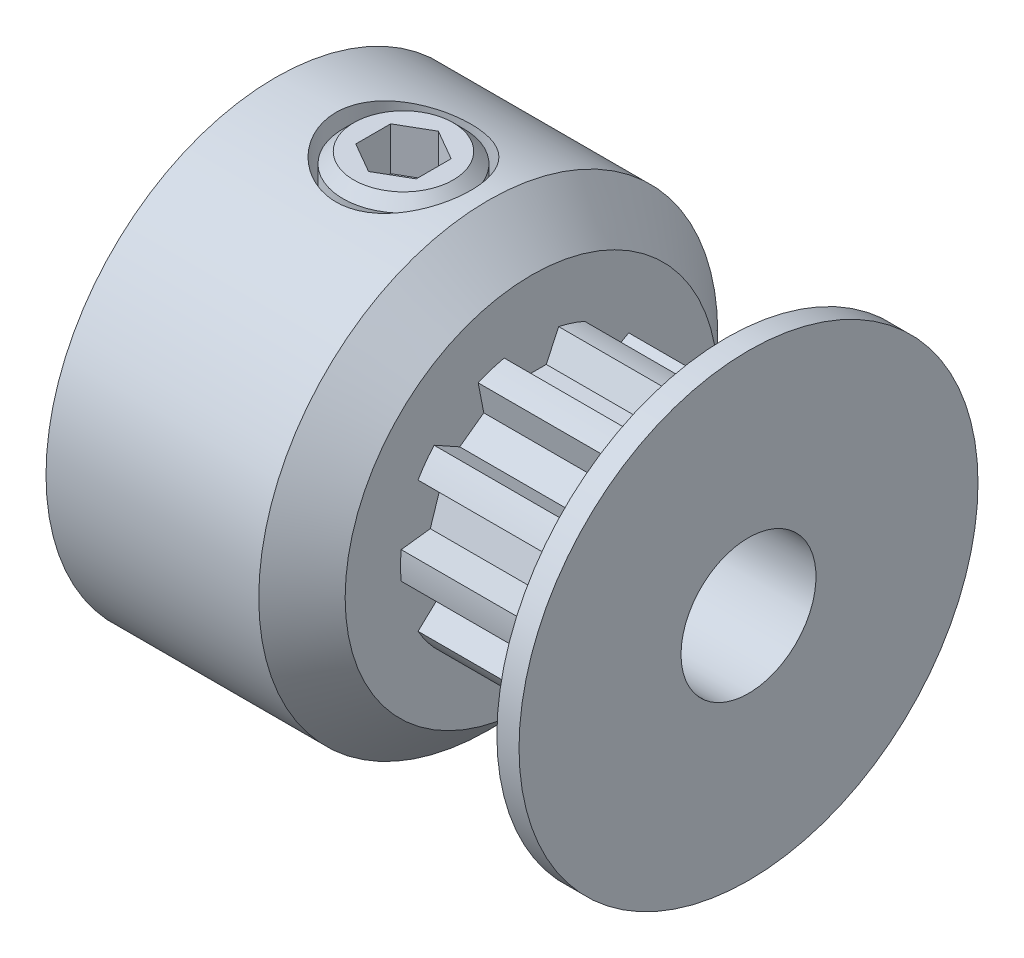
from build123d import *

# Parameters (mm, degrees)
SKETCH4_R          = 3.2385
SKETCH4_R_2        = 3.07975
CUT_EXTRUDE2_DEPTH = 4.064
CUT_EXTRUDE1_DEPTH = 4.064
CIRPATTERN1_COUNT  = 10
SKETCH6_R          = 1.5875
CUT_EXTRUDE3_DEPTH = 6.3975
CUT_EXTRUDE4_DEPTH = 1.016


with BuildPart() as part:
    # Sketch1 → Revolve1 (revolve)
    with BuildSketch(Plane.XY):
        with BuildLine():
            Line((-5.5626, 1.5875), (5.5626, 1.5875))
            Line((5.5626, 1.5875), (5.5626, 5.3975))
            Line((5.5626, 5.3975), (5.0419, 5.3975))
            ThreePointArc((5.0419, 5.3975), (4.654699632, 4.645356921), (4.5212, 3.81))
            Line((4.5212, 3.81), (4.5212, 3.2385))
            Line((4.5212, 3.2385), (0.4572, 3.2385))
            Line((0.4572, 3.2385), (0.4572, 4.3815))
            Line((0.4572, 4.3815), (-0.5588, 5.3975))
            Line((-0.5588, 5.3975), (-5.5626, 5.3975))
            Line((-5.5626, 5.3975), (-5.5626, 1.5875))
        make_face()
    revolve(axis=Axis((-5.5626, 0, 0), (1, 0, 0)))

    # Sketch4 → Cut-Extrude2 (cut)
    with BuildSketch(Plane(origin=(0.4572, 0, 0), x_dir=(0, 0, -1), z_dir=(1, 0, 0))):
        Circle(SKETCH4_R)
        Circle(SKETCH4_R_2, mode=Mode.SUBTRACT)
    extrude(amount=CUT_EXTRUDE2_DEPTH, mode=Mode.SUBTRACT)

    # Sketch3 → Cut-Extrude1 (cut)
    with BuildSketch(Plane(origin=(0.4572, 0, 0), x_dir=(0, 0, -1), z_dir=(1, 0, 0))):
        with BuildLine():
            Line((-0.640454656, 3.012420604), (-0.349102168, 2.387613176))
            Line((-0.349102168, 2.387613176), (0.349102168, 2.387613176))
            Line((0.349102168, 2.387613176), (0.640454656, 3.012420604))
            ThreePointArc((0.640454656, 3.012420604), (0, 3.07975), (-0.640454656, 3.012420604))
        make_face()
    cut_extrude1 = extrude(amount=CUT_EXTRUDE1_DEPTH, mode=Mode.SUBTRACT)

    # CirPattern1: Cut-Extrude1 ×10 about axis
    cirpattern1_axis = Axis((0, 0, 0), (1, 0, 0))
    for i in range(1, CIRPATTERN1_COUNT):
        add(cut_extrude1.rotate(cirpattern1_axis, i * 360 / CIRPATTERN1_COUNT), mode=Mode.SUBTRACT)

    # Sketch6 → Cut-Extrude3 (cut, through all)
    with BuildSketch(Plane(origin=(0, 0, 0), x_dir=(1, 0, 0), z_dir=(0, 1, 0))):
        with Locations((-2.5527, 0)):
            Circle(SKETCH6_R)
    extrude(amount=CUT_EXTRUDE3_DEPTH, mode=Mode.SUBTRACT)


with BuildPart() as body_2:
    # Sketch7 → Revolve2 (revolve)
    with BuildSketch(Plane.XY):
        Polygon((-3.7211, 5.3975), (-2.5527, 5.3975), (-2.5527, 1.9685), (-3.7211, 1.9685), (-3.9751, 2.2225), (-3.9751, 5.1435), align=None)
    revolve(axis=Axis((-2.5527, 1.9685, 0), (0, 1, 0)))

    # Sketch8 → Cut-Extrude4 (cut)
    with BuildSketch(Plane(origin=(0, 5.3975, 0), x_dir=(1, 0, 0), z_dir=(0, 1, 0))):
        Polygon((-2.5527, 0.821223023), (-3.2639, 0.410611511), (-3.2639, -0.410611511), (-2.5527, -0.821223023), (-1.8415, -0.410611511), (-1.8415, 0.410611511), align=None)
    extrude(amount=-CUT_EXTRUDE4_DEPTH, mode=Mode.SUBTRACT)


solid = Compound([part.part, body_2.part])
